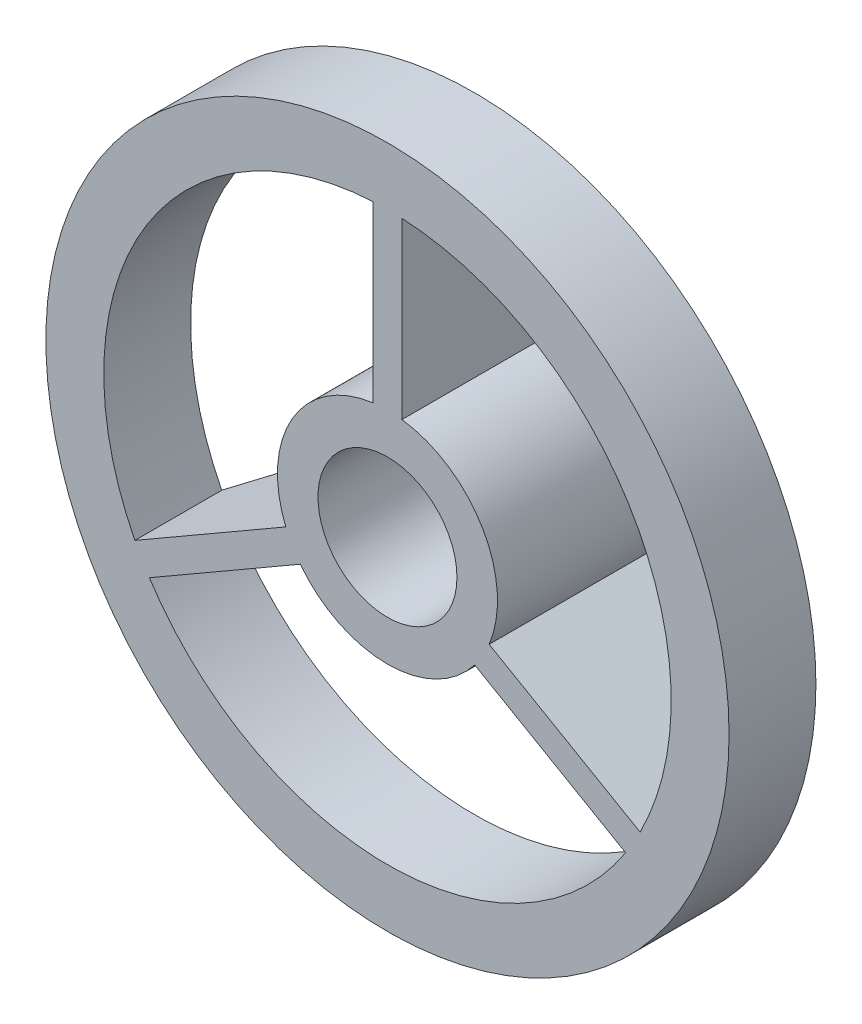
from build123d import *

# Parameters (mm, degrees)
SKETCH1_R           = 1.9
SKETCH1_R_2         = 1.2
BOSS_EXTRUDE1_DEPTH = 3.5
SKETCH3_R           = 5.9
SKETCH3_R_2         = 4.9
BOSS_EXTRUDE3_DEPTH = 1.5
BOSS_EXTRUDE4_DEPTH = 0.25
CIRPATTERN1_COUNT   = 3


with BuildPart() as part:
    # Sketch1 → Boss-Extrude1 (new body)
    with BuildSketch(Plane.XY):
        Circle(SKETCH1_R)
        Circle(SKETCH1_R_2, mode=Mode.SUBTRACT)
    extrude(amount=BOSS_EXTRUDE1_DEPTH)



with BuildPart() as body_2:
    # Sketch3 → Boss-Extrude3 (new body)
    with BuildSketch(Plane.XY.offset(3.5)):
        Circle(SKETCH3_R)
        Circle(SKETCH3_R_2, mode=Mode.SUBTRACT)
    extrude(amount=-BOSS_EXTRUDE3_DEPTH)


with BuildPart() as part_1:
    add(part.part)

    add(body_2.part)  # Boss-Extrude4 merges body 2
    # Sketch8 → Boss-Extrude4 (add, symmetric)
    with BuildSketch(Plane(origin=(0, 0, 0), x_dir=(0, 0, -1), z_dir=(1, 0, 0))):
        Polygon((-2, 4.9), (0, 1.9), (0, 1.7), (-3.5, 1.7), (-3.5, 1.9), (-3.5, 4.9), align=None)
    boss_extrude4 = extrude(amount=BOSS_EXTRUDE4_DEPTH, both=True)

    # CirPattern1: Boss-Extrude4 ×3 about axis
    cirpattern1_axis = Axis((0, 0, 0), (0, 0, 1))
    for i in range(1, CIRPATTERN1_COUNT):
        add(boss_extrude4.rotate(cirpattern1_axis, i * 360 / CIRPATTERN1_COUNT))


solid = part_1.part
